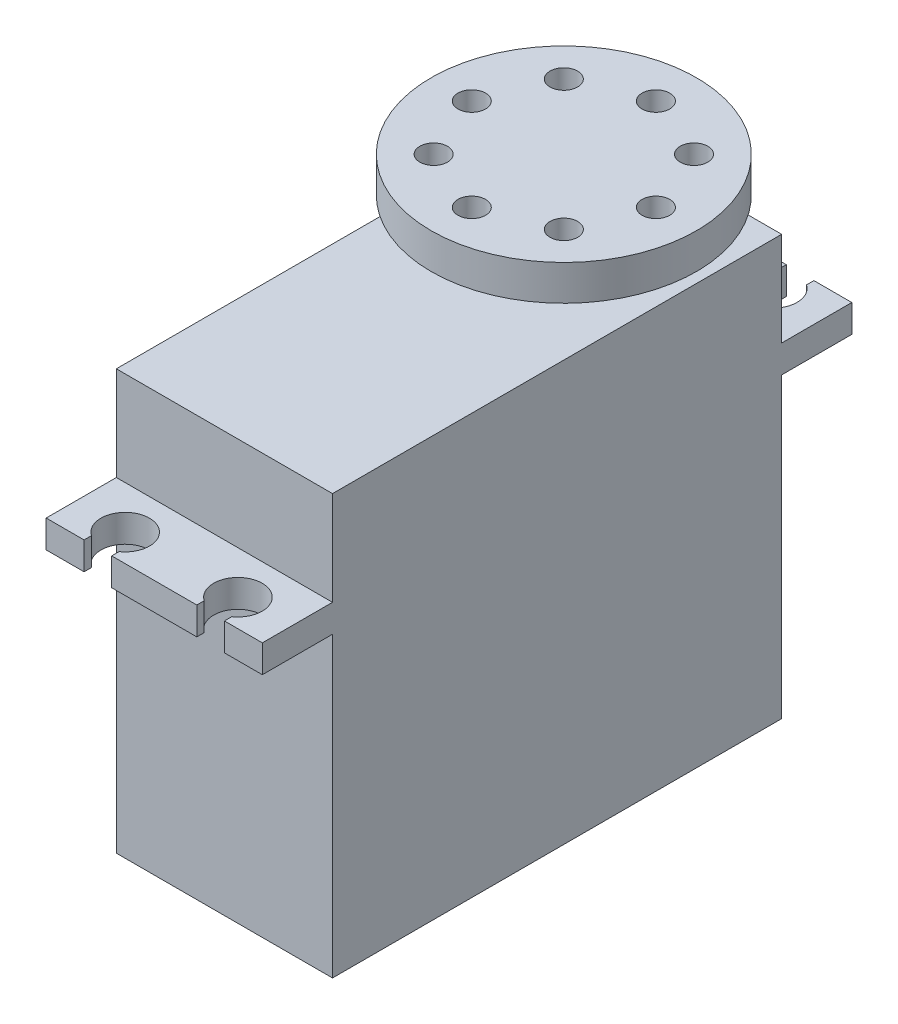
from build123d import *

# Parameters (mm, degrees)
SKETCH1_W           = 19.56
SKETCH1_H           = 40.64
BOSS_EXTRUDE1_DEPTH = 37.96
SKETCH2_W           = 53.34
SKETCH2_H           = 2.5
BOSS_EXTRUDE2_DEPTH = 19.56
SKETCH3_R           = 2.195
CUT_EXTRUDE1_DEPTH  = 30.44
SKETCH4_W           = 2.5
SKETCH4_H           = 0.665692654
CUT_EXTRUDE2_DEPTH  = 30.44
SKETCH5_R           = 6
BOSS_EXTRUDE3_DEPTH = 3.15
SKETCH6_R           = 12
BOSS_EXTRUDE4_DEPTH = 3.2
SKETCH7_R           = 1.25
CUT_EXTRUDE3_DEPTH  = 3.2
SKETCH8_R           = 3.685
BOSS_EXTRUDE5_DEPTH = 4.06


with BuildPart() as part:
    # Sketch1 → Boss-Extrude1 (new body)
    with BuildSketch(Plane(origin=(0, 0, 0), x_dir=(1, 0, 0), z_dir=(0, 1, 0))):
        Rectangle(SKETCH1_W, SKETCH1_H)
    extrude(amount=BOSS_EXTRUDE1_DEPTH)

    # Sketch2 → Boss-Extrude2 (add)
    with BuildSketch(Plane(origin=(9.78, 0, 0), x_dir=(0, 0, -1), z_dir=(1, 0, 0))):
        with Locations((0, 28.19)):
            Rectangle(SKETCH2_W, SKETCH2_H)
    extrude(amount=-BOSS_EXTRUDE2_DEPTH)

    # Sketch3 → Cut-Extrude1 (cut, through all)
    with BuildSketch(Plane(origin=(0, 29.44, 0), x_dir=(1, 0, 0), z_dir=(0, 1, 0))):
        with Locations((-5.1, 24.2)):
            Circle(SKETCH3_R)
        with Locations((5.1, 24.2)):
            Circle(SKETCH3_R)
        with Locations((5.1, -24.2)):
            Circle(SKETCH3_R)
        with Locations((-5.1, -24.2)):
            Circle(SKETCH3_R)
    extrude(amount=-CUT_EXTRUDE1_DEPTH, mode=Mode.SUBTRACT)

    # Sketch4 → Cut-Extrude2 (cut, through all)
    with BuildSketch(Plane(origin=(0, 29.44, 0), x_dir=(1, 0, 0), z_dir=(0, 1, 0))):
        with Locations((5.1, 26.337153673)):
            Rectangle(SKETCH4_W, SKETCH4_H)
        with Locations((-5.1, 26.337153673)):
            Rectangle(SKETCH4_W, SKETCH4_H)
        with Locations((5.1, -26.337153673)):
            Rectangle(SKETCH4_W, SKETCH4_H)
        with Locations((-5.1, -26.337153673)):
            Rectangle(SKETCH4_W, SKETCH4_H)
    extrude(amount=-CUT_EXTRUDE2_DEPTH, mode=Mode.SUBTRACT)

    # Sketch5 → Boss-Extrude3 (add)
    with BuildSketch(Plane(origin=(0, 37.96, 0), x_dir=(1, 0, 0), z_dir=(0, 1, 0))):
        with Locations((0, 10.39)):
            Circle(SKETCH5_R)
    extrude(amount=BOSS_EXTRUDE3_DEPTH)

    # Sketch6 → Boss-Extrude4 (add)
    with BuildSketch(Plane(origin=(0, 41.11, 0), x_dir=(1, 0, 0), z_dir=(0, 1, 0))):
        with Locations((0, 10.39)):
            Circle(SKETCH6_R)
    extrude(amount=BOSS_EXTRUDE4_DEPTH)

    # Sketch7 → Cut-Extrude3 (cut)
    with BuildSketch(Plane(origin=(0, 44.31, 0), x_dir=(1, 0, 0), z_dir=(0, 1, 0))):
        with Locations((0, 18.72)):
            Circle(SKETCH7_R)
        with Locations((5.890199487, 16.280199487)):
            Circle(SKETCH7_R)
        with Locations((8.33, 10.39)):
            Circle(SKETCH7_R)
        with Locations((5.890199487, 4.499800513)):
            Circle(SKETCH7_R)
        with Locations((0, 2.06)):
            Circle(SKETCH7_R)
        with Locations((-5.890199487, 4.499800513)):
            Circle(SKETCH7_R)
        with Locations((-8.33, 10.39)):
            Circle(SKETCH7_R)
        with Locations((-5.890199487, 16.280199487)):
            Circle(SKETCH7_R)
    extrude(amount=-CUT_EXTRUDE3_DEPTH, mode=Mode.SUBTRACT)

    # Sketch8 → Boss-Extrude5 (add)
    with BuildSketch(Plane.XZ):
        with Locations((0, -10.39)):
            Circle(SKETCH8_R)
    extrude(amount=BOSS_EXTRUDE5_DEPTH)


solid = part.part
